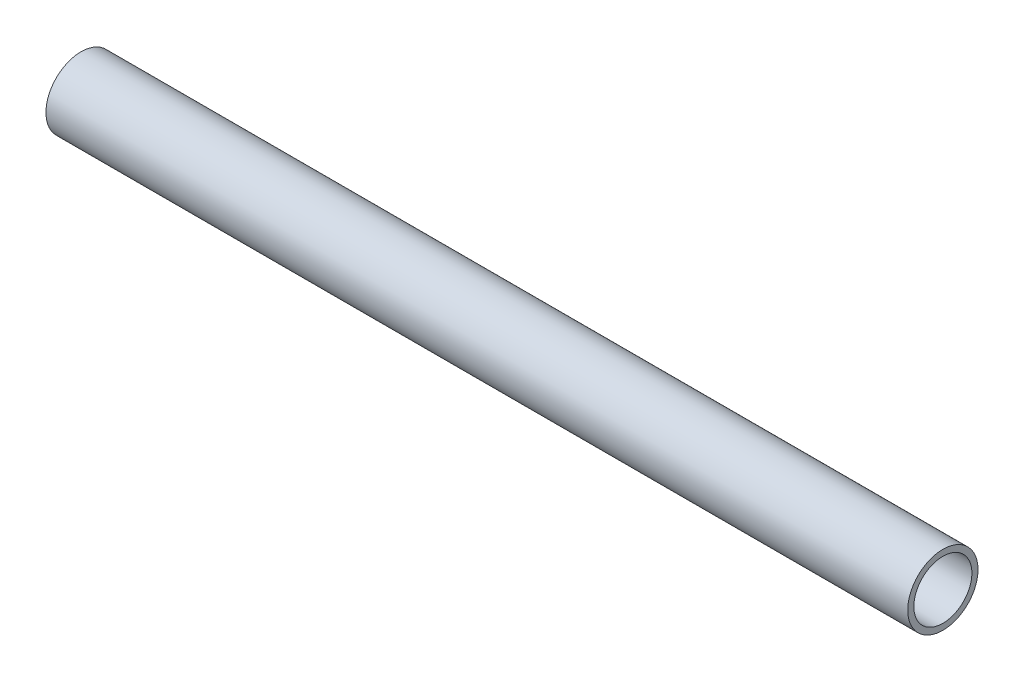
from build123d import *

# Parameters (mm, degrees)
SKETCH1_R           = 9.525
SKETCH1_R_2         = 7.874
BOSS_EXTRUDE1_DEPTH = 116.84


with BuildPart() as part:
    # Sketch1 → Boss-Extrude1 (new body, symmetric)
    with BuildSketch(Plane(origin=(0, 0, 0), x_dir=(0, 0, -1), z_dir=(1, 0, 0))):
        Circle(SKETCH1_R)
        Circle(SKETCH1_R_2, mode=Mode.SUBTRACT)
    extrude(amount=BOSS_EXTRUDE1_DEPTH, both=True)


solid = part.part
